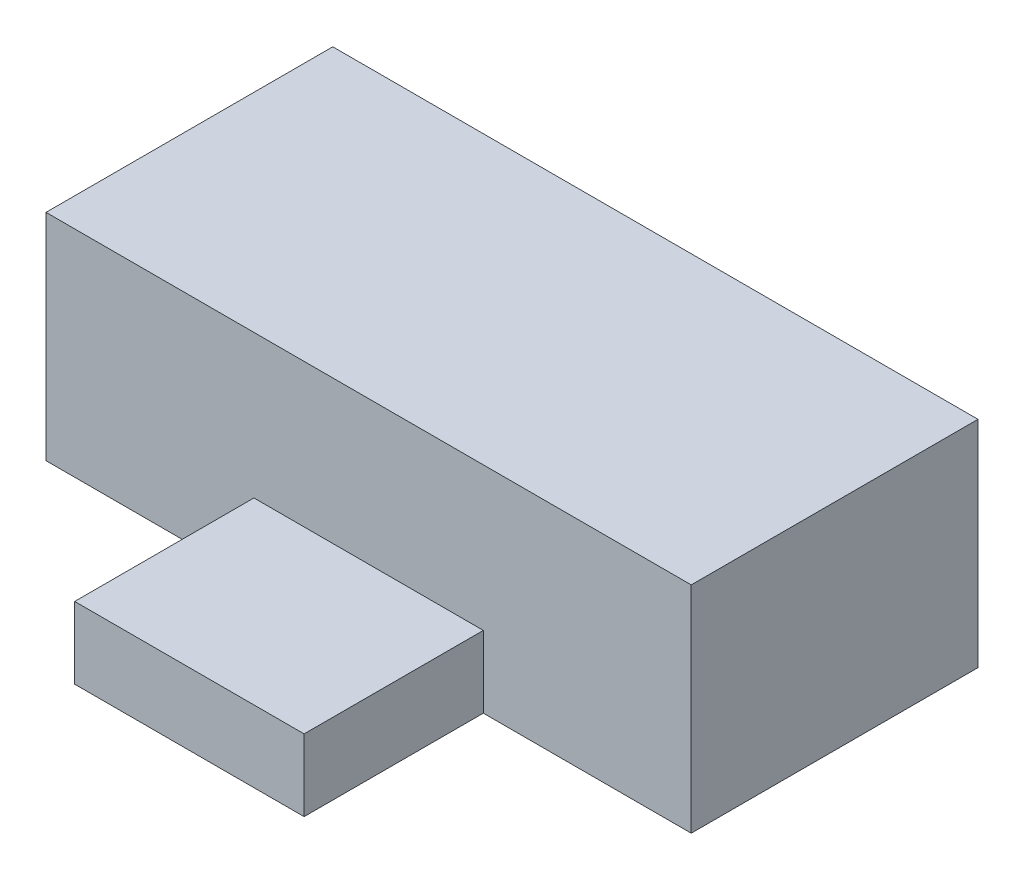
from build123d import *

# Parameters (mm, degrees)
ESQUISSE1_W        = 18
ESQUISSE1_H        = 8
BOSS_EXTRU_1_DEPTH = 6
ESQUISSE2_W        = 6.4
ESQUISSE2_H        = 2
BOSS_EXTRU_2_DEPTH = 5


with BuildPart() as part:
    # Esquisse1 → Boss.-Extru.1 (new body)
    with BuildSketch(Plane(origin=(0, 0, 0), x_dir=(1, 0, 0), z_dir=(0, 1, 0))):
        Rectangle(ESQUISSE1_W, ESQUISSE1_H)
    extrude(amount=BOSS_EXTRU_1_DEPTH)

    # Esquisse2 → Boss.-Extru.2 (add)
    with BuildSketch(Plane.XY.offset(4)):
        with Locations((0, 1)):
            Rectangle(ESQUISSE2_W, ESQUISSE2_H)
    extrude(amount=BOSS_EXTRU_2_DEPTH)


solid = part.part
